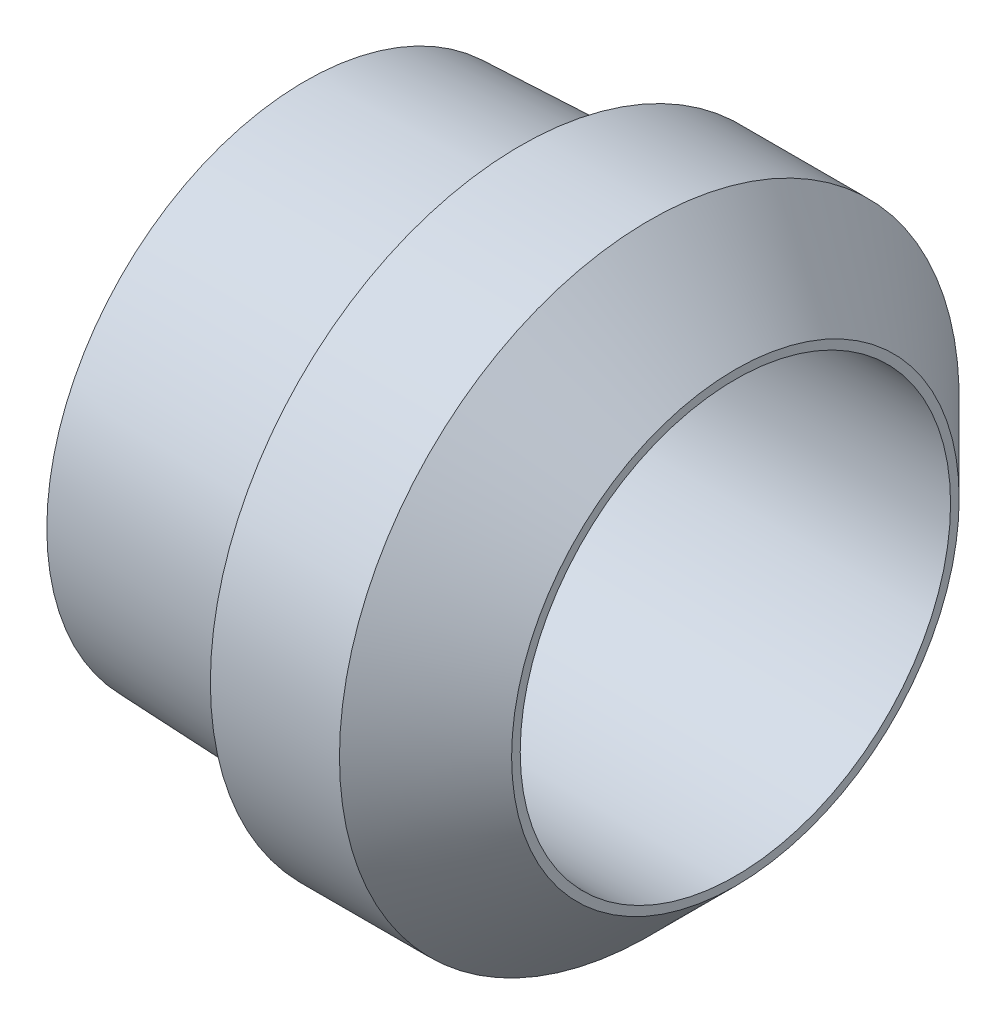
from build123d import *


with BuildPart() as part:
    # Sketch1 → Base-Revolve (revolve)
    with BuildSketch(Plane.XY):
        Polygon((0, 5), (0, 6), (5, 6.2), (5, 7.2), (8, 7.2), (10, 5.2), (10, 5), align=None)
    revolve(axis=Axis((-12, 0, 0), (1, 0, 0)))


solid = part.part
